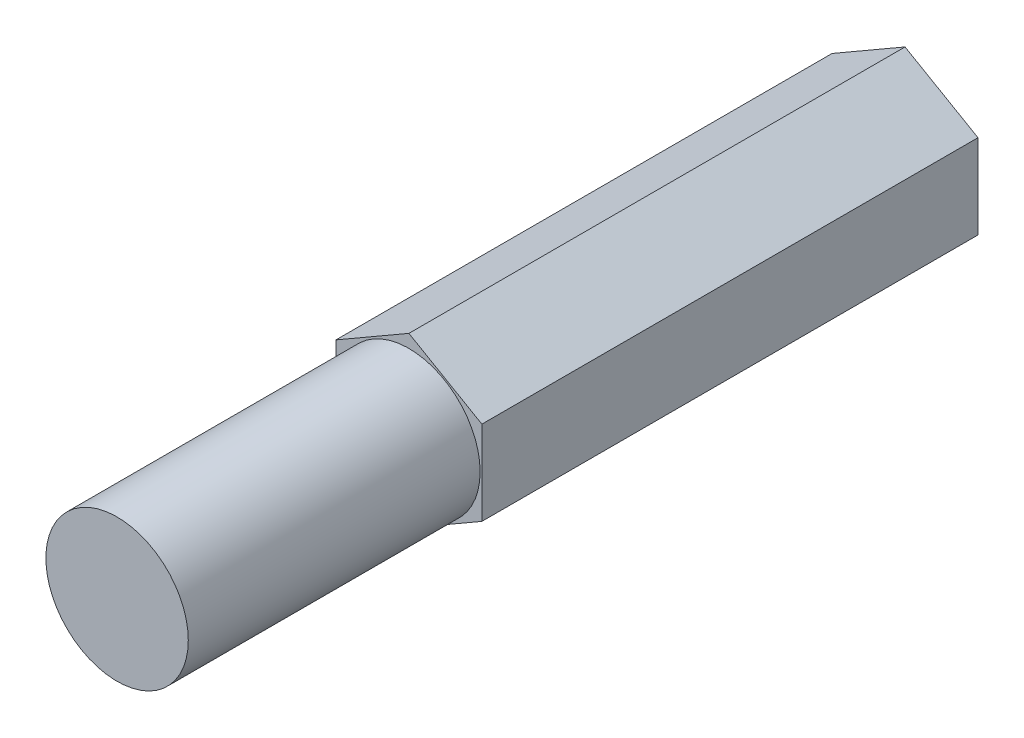
from build123d import *

# Parameters (mm, degrees)
SKETCH1_R           = 3.0988
BOSS_EXTRUDE1_DEPTH = 12.7
BOSS_EXTRUDE2_DEPTH = 21.59


with BuildPart() as part:
    # Sketch1 → Boss-Extrude1 (new body)
    with BuildSketch(Plane.XY):
        Circle(SKETCH1_R)
    extrude(amount=-BOSS_EXTRUDE1_DEPTH)

    # Sketch2 → Boss-Extrude2 (add)
    with BuildSketch(Plane(origin=(0, 0, -12.7), x_dir=(-1, 0, 0), z_dir=(0, 0, -1))):
        Polygon((0, 3.666174209), (-3.175, 1.833087105), (-3.175, -1.833087105), (0, -3.666174209), (3.175, -1.833087105), (3.175, 1.833087105), align=None)
    extrude(amount=BOSS_EXTRUDE2_DEPTH)


solid = part.part
